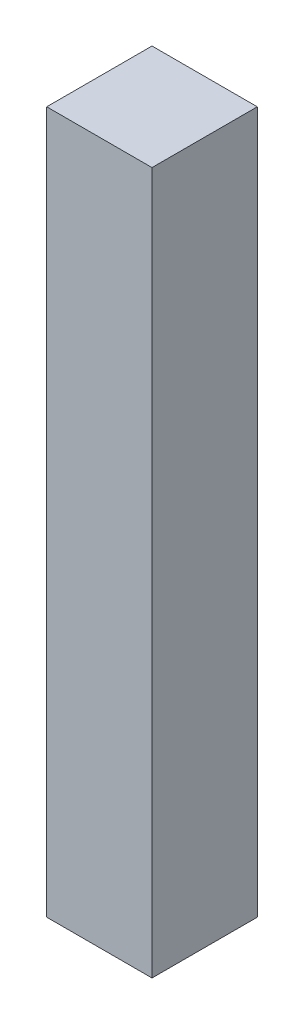
from build123d import *

# Parameters (mm, degrees)
SKETCH1_W           = 60
SKETCH1_H           = 60
BOSS_EXTRUDE1_DEPTH = 400


with BuildPart() as part:
    # Sketch1 → Boss-Extrude1 (new body)
    with BuildSketch(Plane(origin=(0, 0, 0), x_dir=(1, 0, 0), z_dir=(0, 1, 0))):
        Rectangle(SKETCH1_W, SKETCH1_H)
    extrude(amount=BOSS_EXTRUDE1_DEPTH)


solid = part.part
